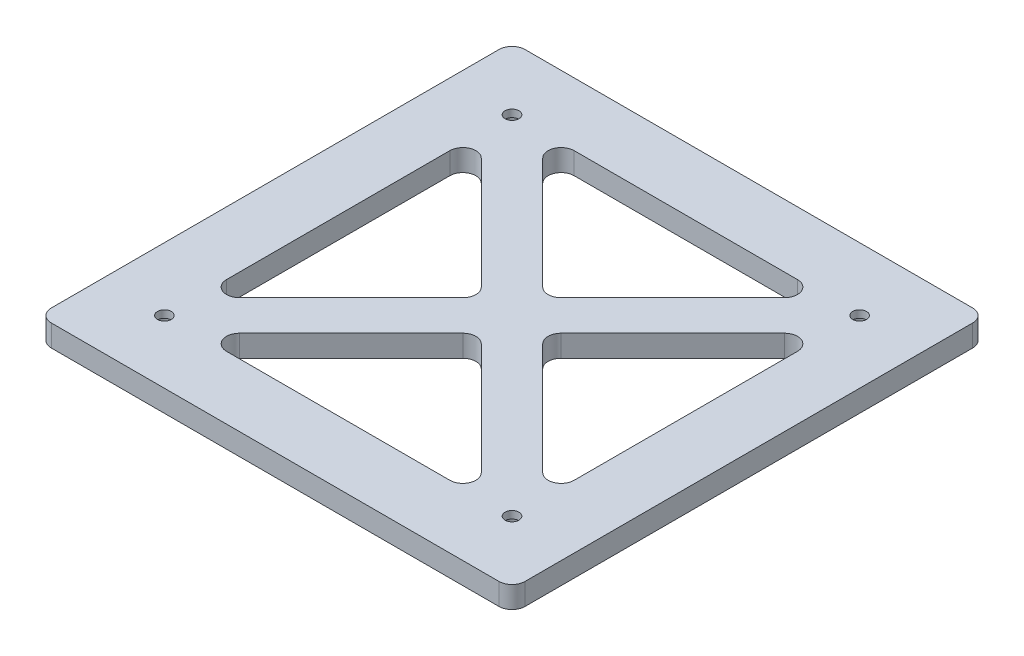
from build123d import *

# Parameters (mm, degrees)
SKETCH_1_W          = 109
SKETCH_1_H          = 109
SKETCH_1_R          = 1.6
EXTRUDE_2_DEPTH     = 5
FILLET_1_R          = 3
SKETCH_2_R          = 3
CUT_EXTRUDE_1_DEPTH = 3.3


with BuildPart() as part:
    # 草图1 → 凸台-拉伸2 (new body)
    with BuildSketch(Plane(origin=(0, 0, 0), x_dir=(1, 0, 0), z_dir=(0, 1, 0))):
        with Locations((54.5, 54.5)):
            Rectangle(SKETCH_1_W, SKETCH_1_H)
        with Locations((14.5, 94.5)):
            Circle(SKETCH_1_R, mode=Mode.SUBTRACT)
        with Locations((94.5, 94.5)):
            Circle(SKETCH_1_R, mode=Mode.SUBTRACT)
        with Locations((94.5, 14.5)):
            Circle(SKETCH_1_R, mode=Mode.SUBTRACT)
        with Locations((14.5, 14.5)):
            Circle(SKETCH_1_R, mode=Mode.SUBTRACT)
        Polygon((14.5, 87.428932188), (47.428932188, 54.5), (14.5, 21.571067812), align=None, mode=Mode.SUBTRACT)
        Polygon((21.571067812, 94.5), (87.428932188, 94.5), (54.5, 61.571067812), align=None, mode=Mode.SUBTRACT)
        Polygon((94.5, 87.428932188), (94.5, 21.571067812), (61.571067812, 54.5), align=None, mode=Mode.SUBTRACT)
        Polygon((87.428932188, 14.5), (21.571067812, 14.5), (54.5, 47.428932188), align=None, mode=Mode.SUBTRACT)
    extrude(amount=EXTRUDE_2_DEPTH)

    # 圆角1
    fillet_1_edges = [part.edges().sort_by_distance(p)[0] for p in [
        (14.5, 2.5, -87.428932188),
        (14.5, 2.5, -21.571067812),
        (47.428932188, 2.5, -54.5),
        (54.5, 2.5, -61.571067812),
        (87.428932188, 2.5, -94.5),
        (21.571067812, 2.5, -94.5),
        (61.571067812, 2.5, -54.5),
        (94.5, 2.5, -21.571067812),
        (94.5, 2.5, -87.428932188),
        (54.5, 2.5, -47.428932188),
        (21.571067812, 2.5, -14.5),
        (87.428932188, 2.5, -14.5),
        (0, 2.5, -109),
        (109, 2.5, -109),
        (109, 2.5, 0),
        (0, 2.5, 0),
    ]]
    fillet(fillet_1_edges, radius=FILLET_1_R)

    # 草图2 → 切除-拉伸1 (cut)
    with BuildSketch(Plane.XZ):
        with Locations((14.5, -14.5)):
            Circle(SKETCH_2_R)
        with Locations((94.5, -14.5)):
            Circle(SKETCH_2_R)
        with Locations((94.5, -94.5)):
            Circle(SKETCH_2_R)
        with Locations((14.5, -94.5)):
            Circle(SKETCH_2_R)
    extrude(amount=-CUT_EXTRUDE_1_DEPTH, mode=Mode.SUBTRACT)


solid = part.part
